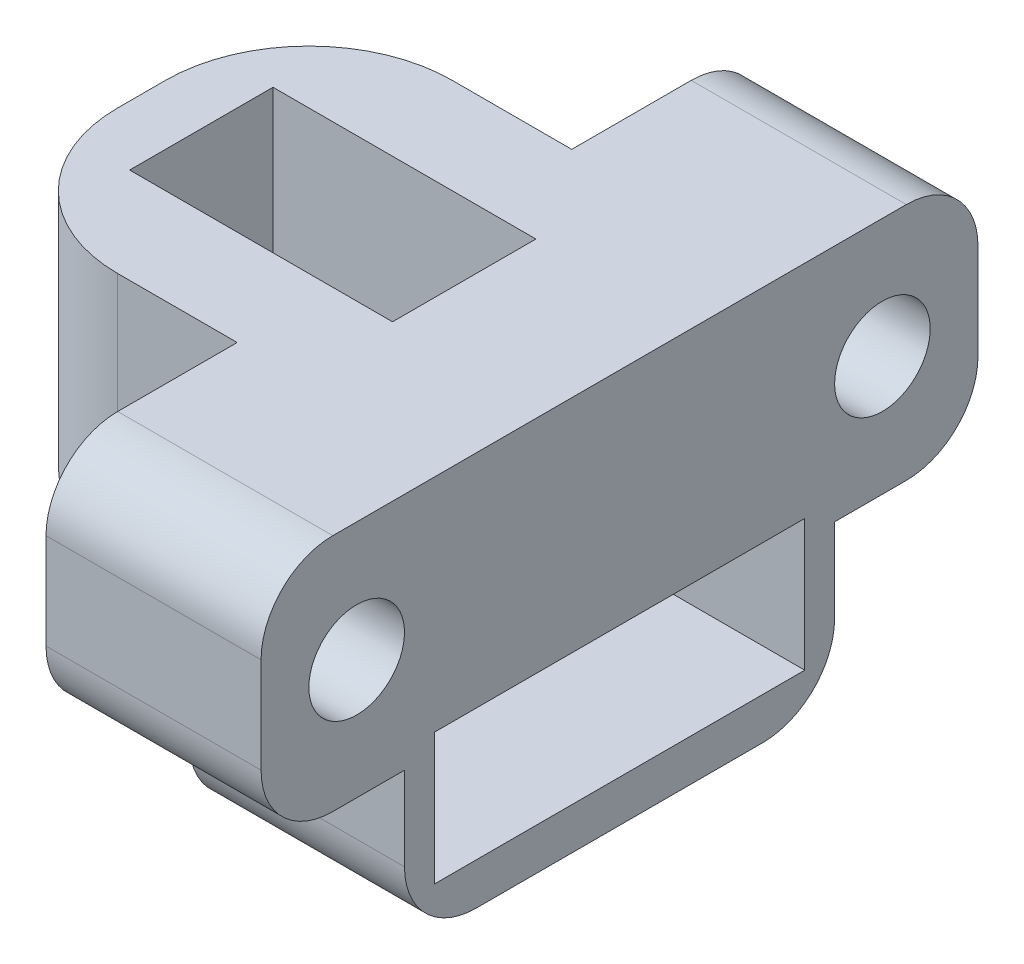
from build123d import *

# Parameters (mm, degrees)
ESBO_O1_W                = 20
ESBO_O1_H                = 30
RESSALTO_EXTRUS_O1_DEPTH = 10
ESBO_O2_W                = 11
ESBO_O2_H                = 8
CORTE_EXTRUS_O1_DEPTH    = 10
ESBO_O3_W                = 11
ESBO_O3_H                = 6
CORTE_EXTRUS_O2_DEPTH    = 7
ESBO_O4_W                = 9
ESBO_O4_H                = 18
RESSALTO_EXTRUS_O2_DEPTH = 6.5
ESBO_O5_W                = 15.5
ESBO_O5_H                = 5.5
CORTE_EXTRUS_O3_DEPTH    = 7.5
ESBO_O6_R                = 2
CORTE_EXTRUS_O4_DEPTH    = 10
ESBO_O7_R                = 3.5
CORTE_EXTRUS_O5_DEPTH    = 2
FILETE1_R                = 6
FILETE2_R                = 3


with BuildPart() as part:
    # Esboço1 → Ressalto-extrusão1 (new body)
    with BuildSketch(Plane(origin=(0, 0, 0), x_dir=(1, 0, 0), z_dir=(0, 1, 0))):
        Rectangle(ESBO_O1_W, ESBO_O1_H)
    extrude(amount=RESSALTO_EXTRUS_O1_DEPTH)

    # Esboço2 → Corte-extrusão1 (cut)
    with BuildSketch(Plane(origin=(0, 10, 0), x_dir=(1, 0, 0), z_dir=(0, 1, 0))):
        with Locations((-4.5, 11)):
            Rectangle(ESBO_O2_W, ESBO_O2_H)
        with Locations((-4.5, -11)):
            Rectangle(ESBO_O2_W, ESBO_O2_H)
    extrude(amount=-CORTE_EXTRUS_O1_DEPTH, mode=Mode.SUBTRACT)

    # Esboço3 → Corte-extrusão2 (cut)
    with BuildSketch(Plane(origin=(0, 10, 0), x_dir=(1, 0, 0), z_dir=(0, 1, 0))):
        with Locations((-2, 0)):
            Rectangle(ESBO_O3_W, ESBO_O3_H)
    extrude(amount=-CORTE_EXTRUS_O2_DEPTH, mode=Mode.SUBTRACT)

    # Esboço4 → Ressalto-extrusão2 (add)
    with BuildSketch(Plane.XZ):
        with Locations((5.5, 0)):
            Rectangle(ESBO_O4_W, ESBO_O4_H)
    extrude(amount=RESSALTO_EXTRUS_O2_DEPTH)

    # Esboço5 → Corte-extrusão3 (cut)
    with BuildSketch(Plane(origin=(10, 0, 0), x_dir=(0, 0, -1), z_dir=(1, 0, 0))):
        with Locations((0, -2)):
            Rectangle(ESBO_O5_W, ESBO_O5_H)
    extrude(amount=-CORTE_EXTRUS_O3_DEPTH, mode=Mode.SUBTRACT)

    # Esboço6 → Corte-extrusão4 (cut, through all)
    with BuildSketch(Plane.ZY.offset(-1)):
        with Locations((11, 5)):
            Circle(ESBO_O6_R)
        with Locations((-11, 5)):
            Circle(ESBO_O6_R)
    extrude(amount=-CORTE_EXTRUS_O4_DEPTH, mode=Mode.SUBTRACT)

    # Esboço7 → Corte-extrusão5 (cut)
    with BuildSketch(Plane.ZY.offset(-1)):
        with Locations((11, 5)):
            Circle(ESBO_O7_R)
        with Locations((-11, 5)):
            Circle(ESBO_O7_R)
    extrude(amount=-CORTE_EXTRUS_O5_DEPTH, mode=Mode.SUBTRACT)

    # Filete1
    filete1_edges = [part.edges().sort_by_distance(p)[0] for p in [
        (-10, 5, -7),
        (-10, 5, 7),
    ]]
    fillet(filete1_edges, radius=FILETE1_R)

    # Filete2
    filete2_edges = [part.edges().sort_by_distance(p)[0] for p in [
        (5.5, 0, 15),
        (5.5, 10, 15),
        (5.5, 0, -15),
        (5.5, -6.5, -9),
        (5.5, -6.5, 9),
        (5.5, 10, -15),
    ]]
    fillet(filete2_edges, radius=FILETE2_R)


solid = part.part
